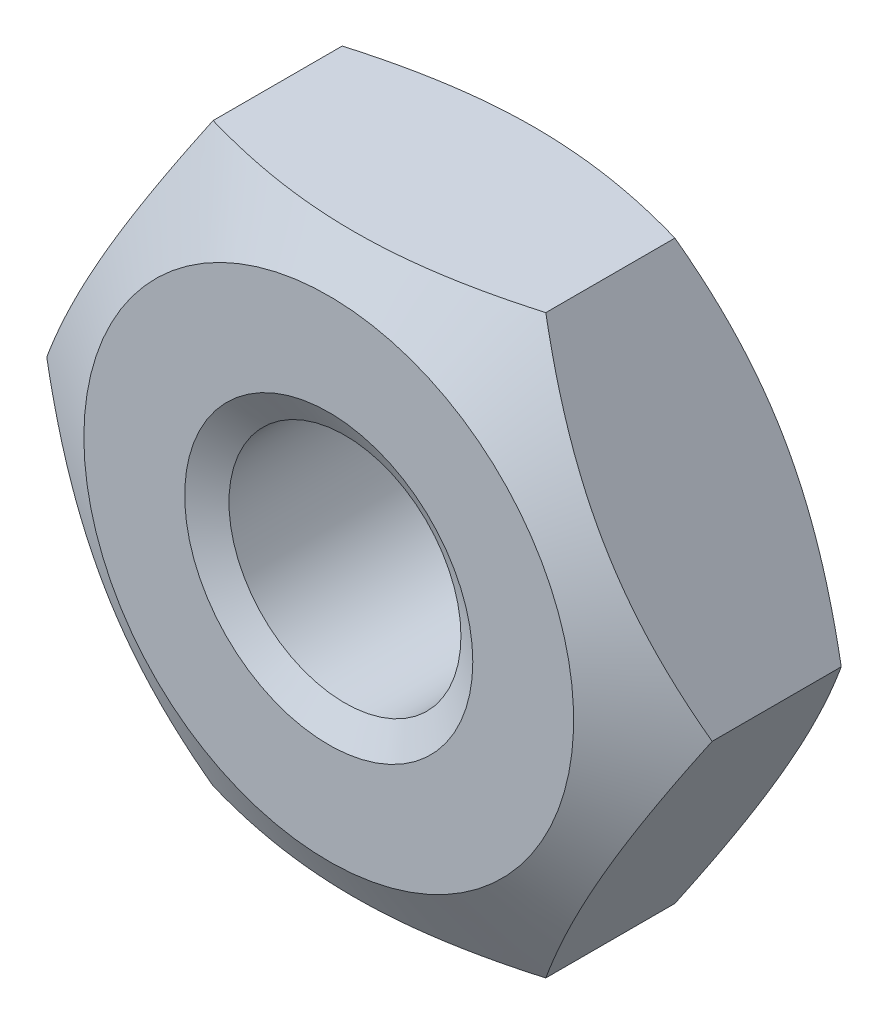
from build123d import *

# Parameters (mm, degrees)
SKETCH1_R               = 1.0065
BASENUT_DEPTH           = 2
ENDCHAMFER_SIZE         = 0.2435
ENDCHAMFER_SIZE2        = 0.140584791
ENDCHAMFER_PART_2_SIZE  = 0.2435
ENDCHAMFER_PART_2_SIZE2 = 0.140584791


with BuildPart() as part:
    # Sketch1 → BaseNut (new body)
    with BuildSketch(Plane.XY):
        Polygon((2.886751346, 0), (1.443375673, 2.5), (-1.443375673, 2.5), (-2.886751346, 0), (-1.443375673, -2.5), (1.443375673, -2.5), align=None)
        Circle(SKETCH1_R, mode=Mode.SUBTRACT)
    extrude(amount=-BASENUT_DEPTH)

    # Sketch2 → Double-Chamfer (revolve, cut)
    with BuildSketch(Plane(origin=(0, 0, 0), x_dir=(1, 0, 0), z_dir=(0, 1, 0))):
        Polygon((-2.886751346, 2), (-2.125, 2), (-2.886751346, 1.560202655), align=None)
        Polygon((-2.886751346, 0.439797345), (-2.886751346, 0), (-2.125, 0), align=None)
    revolve(axis=Axis((0, 0, -3.375940562), (0, 0, 1)), mode=Mode.SUBTRACT)

    # EndChamfer
    endchamfer_edges = [part.edges().sort_by_distance(p)[0] for p in [
        (-1.0065, 0, -2),
    ]]
    endchamfer_side = [part.faces().sort_by_distance(p)[0] for p in [
        (-1.0065, 0, -1),
    ]]
    chamfer(endchamfer_edges, length=ENDCHAMFER_SIZE, length2=ENDCHAMFER_SIZE2, reference=endchamfer_side[0])

    # EndChamfer part 2
    endchamfer_part_2_edges = [part.edges().sort_by_distance(p)[0] for p in [
        (-1.0065, 0, 0),
    ]]
    endchamfer_part_2_side = [part.faces().sort_by_distance(p)[0] for p in [
        (2.064895924, 0, 0),
    ]]
    chamfer(endchamfer_part_2_edges, length=ENDCHAMFER_PART_2_SIZE, length2=ENDCHAMFER_PART_2_SIZE2, reference=endchamfer_part_2_side[0])


solid = part.part
